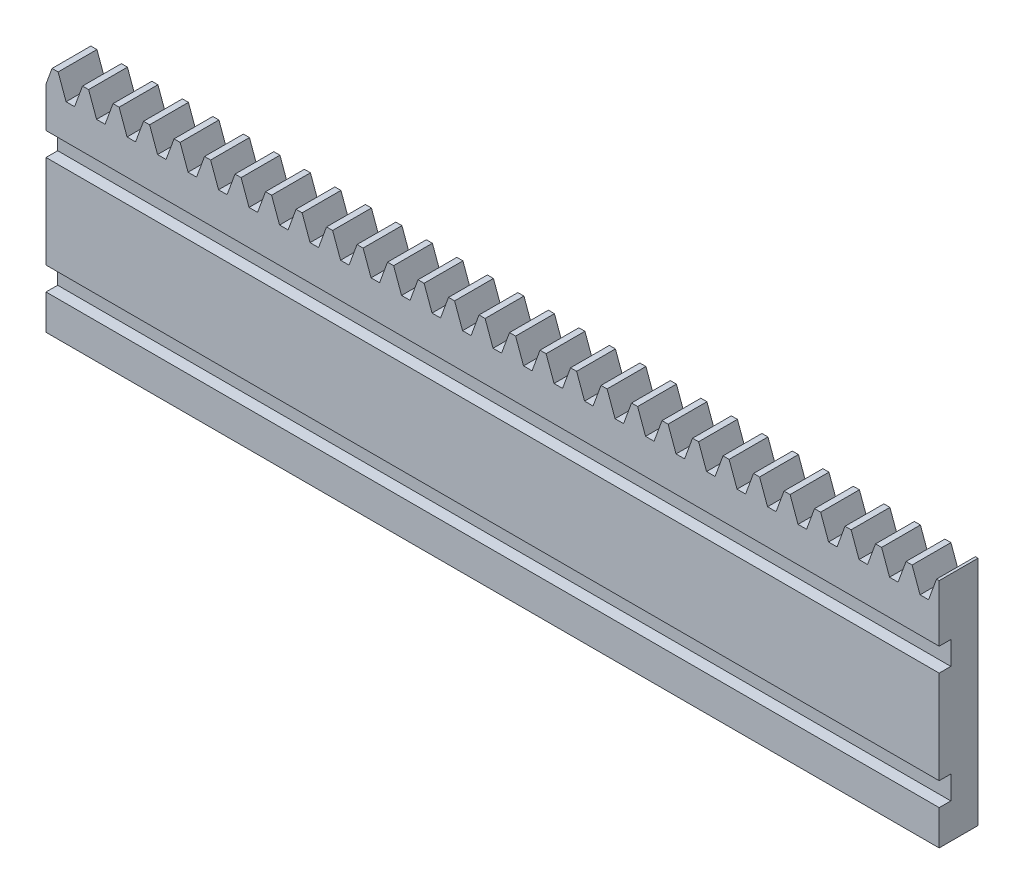
from build123d import *

# Parameters (mm, degrees)
BLANKSKE_W                    = 320
BLANKSKE_H                    = 41.25
BLANK_DEPTH                   = 5
TOOTHCUTSIM_DEPTH             = 323.686477095
TEETHCUTS_COUNT               = 83
TEETHCUTS_PITCH               = 3.926990813
SCHIZZO4_W                    = 5
SCHIZZO4_H                    = 11.438
TAGLIO_ESTRUSIONE1_DEPTH      = 359
SCHIZZO5_W                    = 1.5
SCHIZZO5_H                    = 3
TAGLIO_ESTRUSIONE2_DEPTH      = 323.686477095
TAGLIO_ESTRUSIONE3_DEPTH      = 10
TAGLIO_ESTRUSIONE3_DEPTH_BACK = 10
SCHIZZO6_OUTSIDE_W            = 386.284
SCHIZZO6_OUTSIDE_H            = 96.096
SCHIZZO6_OUTSIDE_W_2          = 115
SCHIZZO6_OUTSIDE_H_2          = 29.812


with BuildPart() as part:
    # BlankSke → Blank (new body)
    with BuildSketch(Plane.XY):
        with Locations((160, 20.625)):
            Rectangle(BLANKSKE_W, BLANKSKE_H)
    extrude(amount=-BLANK_DEPTH)

    # TooCutSkeSim → ToothCutSim (cut, through all)
    with BuildSketch(Plane.XY):
        Polygon((0.548044212, 38.4375), (-0.548044212, 38.4375), (-1.58095534, 41.2754), (1.58095534, 41.2754), align=None)
    toothcutsim = extrude(amount=-TOOTHCUTSIM_DEPTH, mode=Mode.SUBTRACT)

    # TeethCuts: ToothCutSim ×83
    with Locations(*[(i * TEETHCUTS_PITCH, 0, 0) for i in range(1, TEETHCUTS_COUNT)]):
        add(toothcutsim, mode=Mode.SUBTRACT)

    # Schizzo4 → Taglio-Estrusione1 (cut)
    with BuildSketch(Plane(origin=(320, 0, 0), x_dir=(0, 0, -1), z_dir=(1, 0, 0))):
        with Locations((2.5, 5.719)):
            Rectangle(SCHIZZO4_W, SCHIZZO4_H)
    extrude(amount=-TAGLIO_ESTRUSIONE1_DEPTH, mode=Mode.SUBTRACT)

    # Schizzo5 → Taglio-Estrusione2 (cut, through all)
    with BuildSketch(Plane(origin=(320, 0, 0), x_dir=(0, 0, -1), z_dir=(1, 0, 0))):
        with Locations((0.75, 32.437)):
            Rectangle(SCHIZZO5_W, SCHIZZO5_H)
        with Locations((0.75, 17.438)):
            Rectangle(SCHIZZO5_W, SCHIZZO5_H)
    extrude(amount=-TAGLIO_ESTRUSIONE2_DEPTH, mode=Mode.SUBTRACT)

    # Schizzo6 outside → Taglio-Estrusione3 (cut, two sides: drawn at the far end of the back side and taken through both)
    with BuildSketch(Plane(origin=(0, 0, -5), x_dir=(-1, 0, 0), z_dir=(0, 0, -1)).offset(-TAGLIO_ESTRUSIONE3_DEPTH_BACK)):
        with Locations((-160, 26.344)):
            Rectangle(SCHIZZO6_OUTSIDE_W, SCHIZZO6_OUTSIDE_H)
        with Locations((-262.5, 26.344)):
            Rectangle(SCHIZZO6_OUTSIDE_W_2, SCHIZZO6_OUTSIDE_H_2, mode=Mode.SUBTRACT)
    extrude(amount=TAGLIO_ESTRUSIONE3_DEPTH + TAGLIO_ESTRUSIONE3_DEPTH_BACK, mode=Mode.SUBTRACT)


solid = part.part
